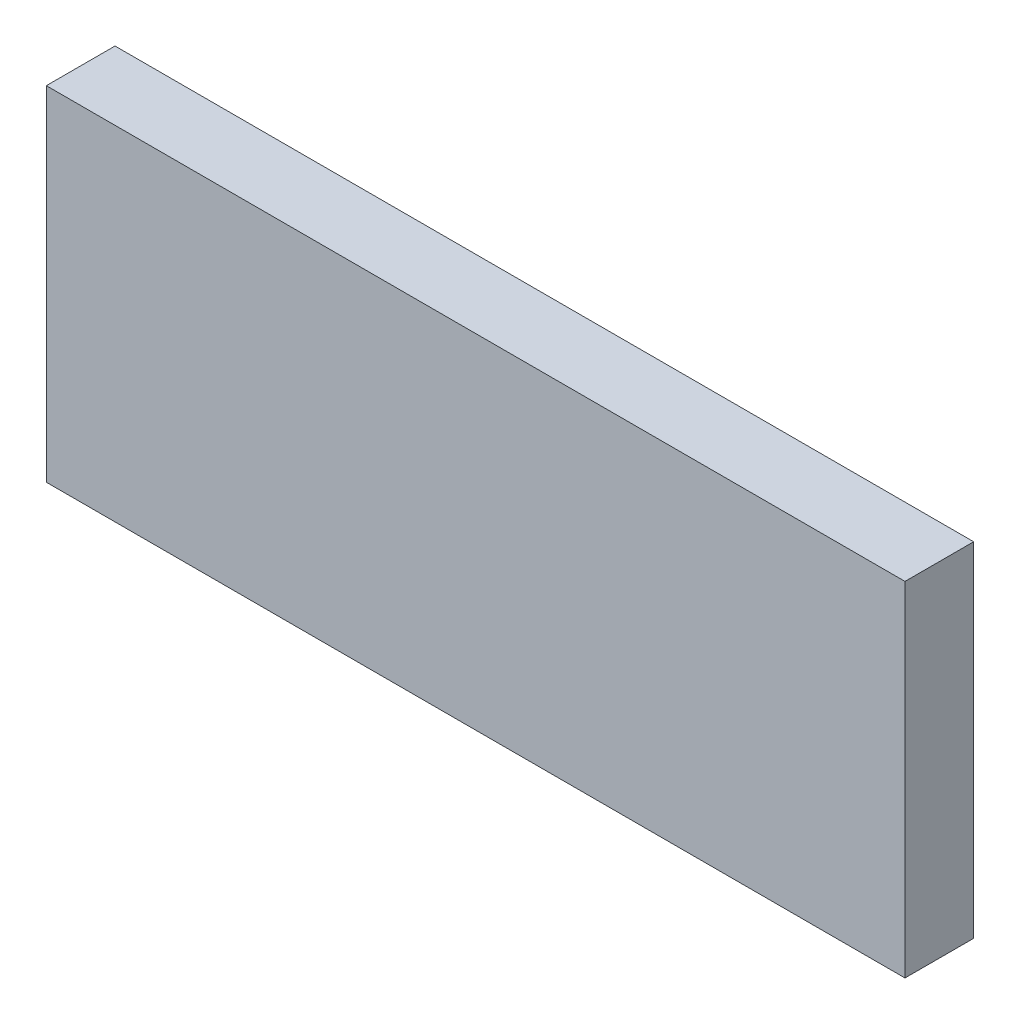
from build123d import *

# Parameters (mm, degrees)
SKETCH_1_W      = 625
SKETCH_1_H      = 250
EXTRUDE_1_DEPTH = 50


with BuildPart() as part:
    # Эскиз1 → Бобышка-Вытянуть1 (new body)
    with BuildSketch(Plane.XY):
        with Locations((312.5, 125)):
            Rectangle(SKETCH_1_W, SKETCH_1_H)
    extrude(amount=EXTRUDE_1_DEPTH)


solid = part.part
